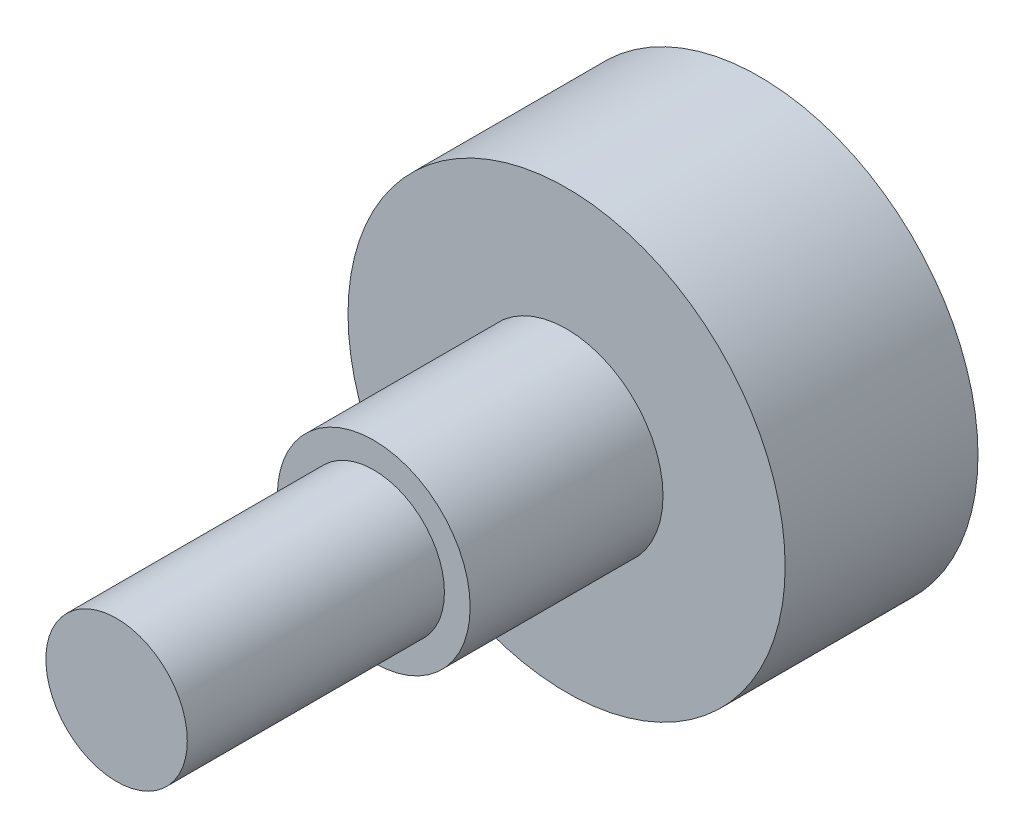
from build123d import *

# Parameters (mm, degrees)
ESQUISSE1_R        = 8.5
BOSS_EXTRU_1_DEPTH = 7.5
ESQUISSE2_R        = 3.75
BOSS_EXTRU_2_DEPTH = 7.5
ESQUISSE3_R        = 2.75
BOSS_EXTRU_3_DEPTH = 10


with BuildPart() as part:
    # Esquisse1 → Boss.-Extru.1 (new body)
    with BuildSketch(Plane.XY):
        Circle(ESQUISSE1_R)
    extrude(amount=BOSS_EXTRU_1_DEPTH)

    # Esquisse2 → Boss.-Extru.2 (add)
    with BuildSketch(Plane.XY.offset(7.5)):
        Circle(ESQUISSE2_R)
    extrude(amount=BOSS_EXTRU_2_DEPTH)

    # Esquisse3 → Boss.-Extru.3 (add)
    with BuildSketch(Plane.XY.offset(15)):
        Circle(ESQUISSE3_R)
    extrude(amount=BOSS_EXTRU_3_DEPTH)


solid = part.part
